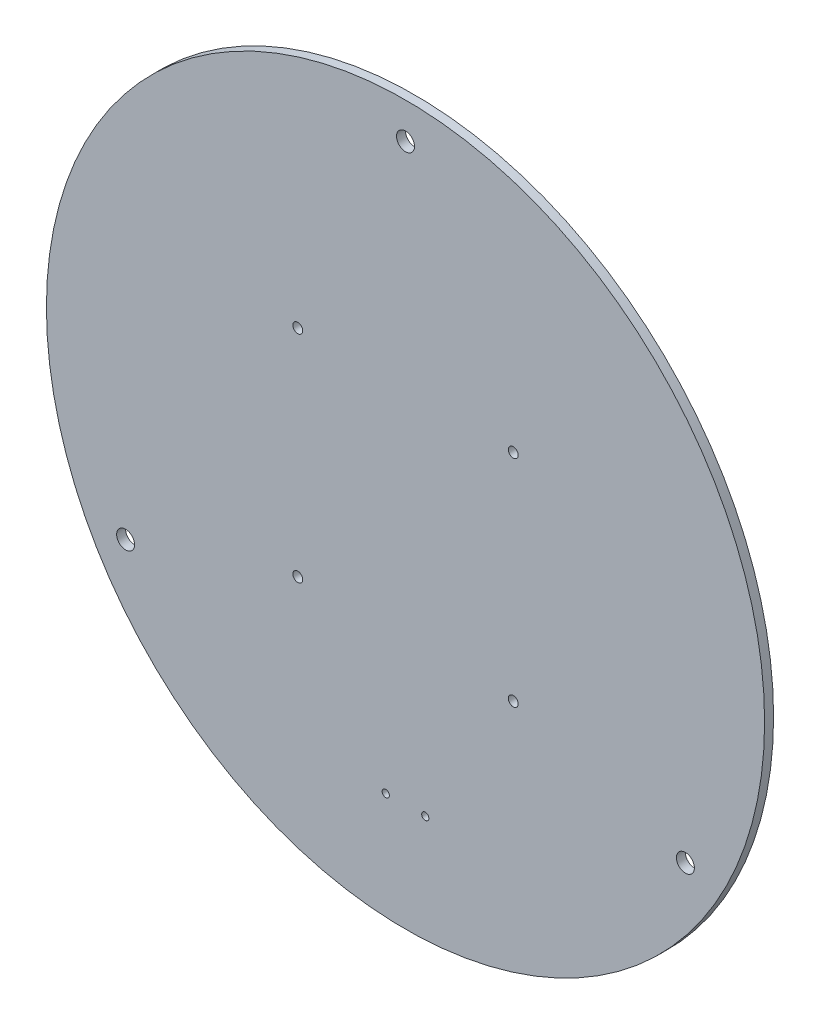
from build123d import *

# Parameters (mm, degrees)
SKETCH1_R           = 200
BOSS_EXTRUDE1_DEPTH = 5
CUT_EXTRUDE1_REACH  = 7
SKETCH2_R           = 5
CUT_EXTRUDE2_REACH  = 7
SKETCH3_R           = 2.75
CUT_EXTRUDE3_REACH  = 7
SKETCH4_R           = 2


with BuildPart() as part:
    # Sketch1 → Boss-Extrude1 (new body)
    with BuildSketch(Plane.XY):
        Circle(SKETCH1_R)
    extrude(amount=BOSS_EXTRUDE1_DEPTH)

    # Sketch2 → Cut-Extrude1 (cut, up to next)
    with BuildSketch(Plane.XY.offset(5), mode=Mode.PRIVATE) as cut_extrude1_sk1:
        with Locations((0, 180)):
            Circle(SKETCH2_R)
    cut_extrude1_tool1 = extrude(cut_extrude1_sk1.sketch, amount=-CUT_EXTRUDE1_REACH, mode=Mode.PRIVATE) & part.part
    add(cut_extrude1_tool1.solids().sort_by_distance((0, 180, 5))[0], mode=Mode.SUBTRACT)
    # Sketch2 → Cut-Extrude1 (cut, up to next)
    with BuildSketch(Plane.XY.offset(5), mode=Mode.PRIVATE) as cut_extrude1_sk2:
        with Locations((155.884572681, -90)):
            Circle(SKETCH2_R)
    cut_extrude1_tool2 = extrude(cut_extrude1_sk2.sketch, amount=-CUT_EXTRUDE1_REACH, mode=Mode.PRIVATE) & part.part
    add(cut_extrude1_tool2.solids().sort_by_distance((155.884573, -90, 5))[0], mode=Mode.SUBTRACT)
    # Sketch2 → Cut-Extrude1 (cut, up to next)
    with BuildSketch(Plane.XY.offset(5), mode=Mode.PRIVATE) as cut_extrude1_sk3:
        with Locations((-155.884572681, -90)):
            Circle(SKETCH2_R)
    cut_extrude1_tool3 = extrude(cut_extrude1_sk3.sketch, amount=-CUT_EXTRUDE1_REACH, mode=Mode.PRIVATE) & part.part
    add(cut_extrude1_tool3.solids().sort_by_distance((-155.884573, -90, 5))[0], mode=Mode.SUBTRACT)

    # Sketch3 → Cut-Extrude2 (cut, up to next)
    with BuildSketch(Plane.XY.offset(5), mode=Mode.PRIVATE) as cut_extrude2_sk1:
        with Locations((-60, 60)):
            Circle(SKETCH3_R)
    cut_extrude2_tool1 = extrude(cut_extrude2_sk1.sketch, amount=-CUT_EXTRUDE2_REACH, mode=Mode.PRIVATE) & part.part
    add(cut_extrude2_tool1.solids().sort_by_distance((-60, 60, 5))[0], mode=Mode.SUBTRACT)
    # Sketch3 → Cut-Extrude2 (cut, up to next)
    with BuildSketch(Plane.XY.offset(5), mode=Mode.PRIVATE) as cut_extrude2_sk2:
        with Locations((60, 60)):
            Circle(SKETCH3_R)
    cut_extrude2_tool2 = extrude(cut_extrude2_sk2.sketch, amount=-CUT_EXTRUDE2_REACH, mode=Mode.PRIVATE) & part.part
    add(cut_extrude2_tool2.solids().sort_by_distance((60, 60, 5))[0], mode=Mode.SUBTRACT)
    # Sketch3 → Cut-Extrude2 (cut, up to next)
    with BuildSketch(Plane.XY.offset(5), mode=Mode.PRIVATE) as cut_extrude2_sk3:
        with Locations((60, -60)):
            Circle(SKETCH3_R)
    cut_extrude2_tool3 = extrude(cut_extrude2_sk3.sketch, amount=-CUT_EXTRUDE2_REACH, mode=Mode.PRIVATE) & part.part
    add(cut_extrude2_tool3.solids().sort_by_distance((60, -60, 5))[0], mode=Mode.SUBTRACT)
    # Sketch3 → Cut-Extrude2 (cut, up to next)
    with BuildSketch(Plane.XY.offset(5), mode=Mode.PRIVATE) as cut_extrude2_sk4:
        with Locations((-60, -60)):
            Circle(SKETCH3_R)
    cut_extrude2_tool4 = extrude(cut_extrude2_sk4.sketch, amount=-CUT_EXTRUDE2_REACH, mode=Mode.PRIVATE) & part.part
    add(cut_extrude2_tool4.solids().sort_by_distance((-60, -60, 5))[0], mode=Mode.SUBTRACT)

    # Sketch4 → Cut-Extrude3 (cut, up to next)
    with BuildSketch(Plane.XY.offset(5), mode=Mode.PRIVATE) as cut_extrude3_sk1:
        with Locations((11, -140)):
            Circle(SKETCH4_R)
    cut_extrude3_tool1 = extrude(cut_extrude3_sk1.sketch, amount=-CUT_EXTRUDE3_REACH, mode=Mode.PRIVATE) & part.part
    add(cut_extrude3_tool1.solids().sort_by_distance((11, -140, 5))[0], mode=Mode.SUBTRACT)
    # Sketch4 → Cut-Extrude3 (cut, up to next)
    with BuildSketch(Plane.XY.offset(5), mode=Mode.PRIVATE) as cut_extrude3_sk2:
        with Locations((-11, -140)):
            Circle(SKETCH4_R)
    cut_extrude3_tool2 = extrude(cut_extrude3_sk2.sketch, amount=-CUT_EXTRUDE3_REACH, mode=Mode.PRIVATE) & part.part
    add(cut_extrude3_tool2.solids().sort_by_distance((-11, -140, 5))[0], mode=Mode.SUBTRACT)


solid = part.part
